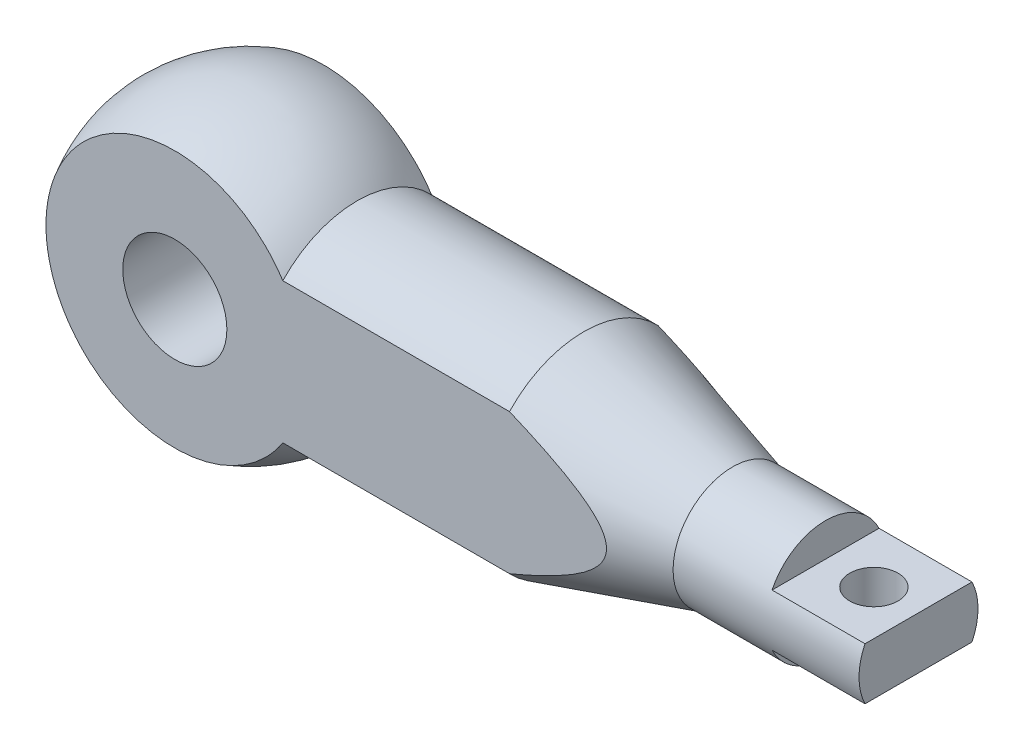
from build123d import *

# Parameters (mm, degrees)
SKETCH_3_OUTSIDE_W       = 271.478
SKETCH_3_OUTSIDE_H       = 131.478
SKETCH_3_OUTSIDE_W_2     = 220
SKETCH_3_OUTSIDE_H_2     = 40
CUT_EXTRUDE_1_DEPTH      = 41
CUT_EXTRUDE_1_DEPTH_BACK = 41
SKETCH_4_R               = 14
SKETCH_4_W               = 25
SKETCH_4_H               = 9
CUT_EXTRUDE_2_DEPTH      = 41
SKETCH_5_R               = 6.5
CUT_EXTRUDE_3_DEPTH      = 48


with BuildPart() as part:
    # 草圖1 → 旋轉1 (revolve)
    with BuildSketch(Plane.XY):
        with BuildLine():
            Line((29.047375097, 27.5), (90, 27.5))
            Line((90, 27.5), (130, 16))
            Line((130, 16), (180, 16))
            Line((180, 16), (180, 0))
            Line((180, 0), (-40, 0))
            ThreePointArc((-40, 0), (-14.800422226, 37.161102001), (29.047375097, 27.5))
        make_face()
    revolve(axis=Axis((-119.807750387, 0, 0), (1, 0, 0)))

    # 草圖3 outside → 除料-伸長1 (cut, two sides)
    with BuildSketch(Plane(origin=(0, 0, 0), x_dir=(1, 0, 0), z_dir=(0, 1, 0))) as cut_extrude_1_sk:
        with Locations((70, 0)):
            Rectangle(SKETCH_3_OUTSIDE_W, SKETCH_3_OUTSIDE_H)
        with Locations((70, 0)):
            Rectangle(SKETCH_3_OUTSIDE_W_2, SKETCH_3_OUTSIDE_H_2, mode=Mode.SUBTRACT)
    extrude(amount=CUT_EXTRUDE_1_DEPTH, mode=Mode.SUBTRACT)
    extrude(cut_extrude_1_sk.sketch, amount=-CUT_EXTRUDE_1_DEPTH_BACK, mode=Mode.SUBTRACT)

    # 草圖4 → 除料-伸長2 (cut, through all)
    with BuildSketch(Plane.XY.offset(20)):
        Circle(SKETCH_4_R)
        with Locations((167.5, 11.5)):
            Rectangle(SKETCH_4_W, SKETCH_4_H)
        with Locations((167.5, -11.5)):
            Rectangle(SKETCH_4_W, SKETCH_4_H)
    extrude(amount=-CUT_EXTRUDE_2_DEPTH, mode=Mode.SUBTRACT)

    # 草圖5 → 除料-伸長3 (cut, through all)
    with BuildSketch(Plane(origin=(0, 7, 0), x_dir=(1, 0, 0), z_dir=(0, 1, 0))):
        with Locations((168, 0)):
            Circle(SKETCH_5_R)
    extrude(amount=-CUT_EXTRUDE_3_DEPTH, mode=Mode.SUBTRACT)


solid = part.part
